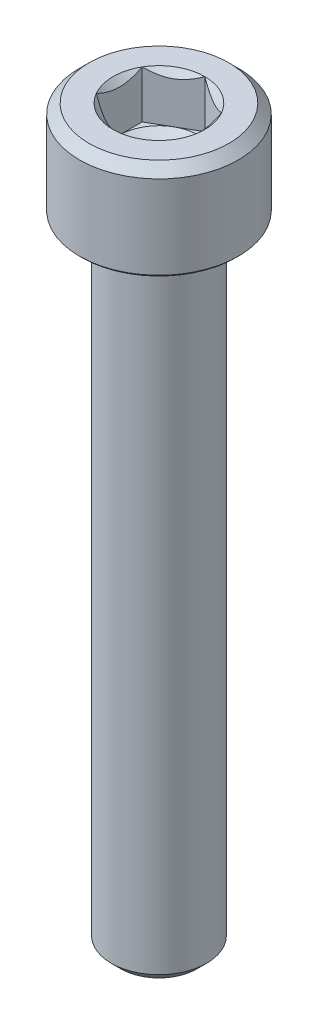
from build123d import *

# Parameters (mm, degrees)
CUT_EXTRUDE1_DEPTH = 3


with BuildPart() as part:
    # Sketch1 → Revolve1 (revolve)
    with BuildSketch(Plane.XY):
        Polygon((0, 1.556624327), (2.5, 3), (2.5, 5.613248654), (2.886751346, 6), (4.4, 6), (5, 5.4), (5, 0.15), (4.85, 0), (3.05, 0), (3, -0.68), (3, -39.3865), (2.3865, -40), (0, -40), align=None)
    revolve(axis=Axis((0, -40, 0), (0, 1, 0)))

    # Sketch2 → Cut-Extrude1 (cut)
    with BuildSketch(Plane(origin=(0, 6, 0), x_dir=(1, 0, 0), z_dir=(0, 1, 0))):
        Polygon((-2.5, -1.443375673), (0, -2.886751346), (2.5, -1.443375673), (2.5, 1.443375673), (0, 2.886751346), (-2.5, 1.443375673), align=None)
    extrude(amount=-CUT_EXTRUDE1_DEPTH, mode=Mode.SUBTRACT)


solid = part.part
